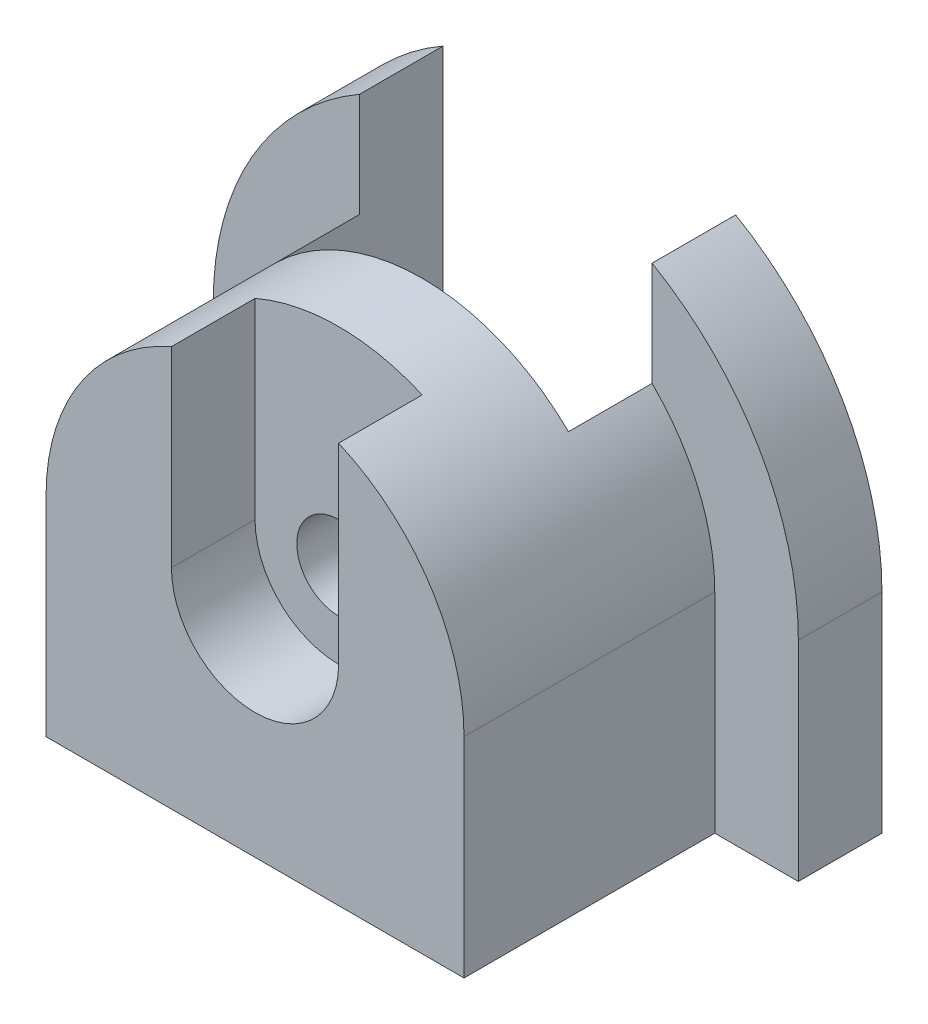
from build123d import *

# Parameters (mm, degrees)
BOSS_EXTRUDE1_DEPTH = 60
SKETCH2_R           = 10
CUT_EXTRUDE1_DEPTH  = 60
CUT_EXTRUDE2_DEPTH  = 20
SKETCH6_R           = 10
CUT_EXTRUDE6_DEPTH  = 20
BOSS_EXTRUDE2_DEPTH = 20
BOSS_EXTRUDE3_DEPTH = 20
SKETCH9_W           = 40
SKETCH9_H           = 10
CUT_EXTRUDE7_DEPTH  = 95


with BuildPart() as part:
    # Sketch1 → Boss-Extrude1 (new body)
    with BuildSketch(Plane.XY):
        with BuildLine():
            ThreePointArc((-50, 0), (0, 50), (50, 0))
            Line((50, 0), (50, -50))
            Line((50, -50), (-50, -50))
            Line((-50, -50), (-50, 0))
        make_face()
    extrude(amount=BOSS_EXTRUDE1_DEPTH)

    # Sketch2 → Cut-Extrude1 (cut)
    with BuildSketch(Plane.XY.offset(60)):
        Circle(SKETCH2_R)
    extrude(amount=-CUT_EXTRUDE1_DEPTH, mode=Mode.SUBTRACT)

    # Sketch3 → Cut-Extrude2 (cut)
    with BuildSketch(Plane.XY.offset(60)):
        with BuildLine():
            Line((-20, 0), (-20, 45.82575695))
            ThreePointArc((-20, 45.82575695), (0, 50), (20, 45.82575695))
            Line((20, 45.82575695), (20, 0))
            ThreePointArc((20, 0), (0, -20), (-20, 0))
        make_face()
    extrude(amount=-CUT_EXTRUDE2_DEPTH, mode=Mode.SUBTRACT)

    # Sketch6 → Cut-Extrude6 (cut)
    with BuildSketch(Plane(origin=(0, 0, 0), x_dir=(-1, 0, 0), z_dir=(0, 0, -1))):
        with BuildLine():
            Line((-35, 35.707142143), (-35, 0))
            ThreePointArc((-35, 0), (0, -35), (35, 0))
            Line((35, 0), (35, 35.707142143))
            ThreePointArc((35, 35.707142143), (0, 50), (-35, 35.707142143))
        make_face()
        Circle(SKETCH6_R, mode=Mode.SUBTRACT)
    extrude(amount=-CUT_EXTRUDE6_DEPTH, mode=Mode.SUBTRACT)

    # Sketch7 → Boss-Extrude2 (add)
    with BuildSketch(Plane(origin=(0, 0, 0), x_dir=(-1, 0, 0), z_dir=(0, 0, -1))):
        with BuildLine():
            Line((-70, -50), (-50, -50))
            Line((-50, -50), (-50, 0))
            ThreePointArc((-50, 0), (-46.097722286, 19.364916731), (-35, 35.707142143))
            Line((-35, 35.707142143), (-35, 60.621778265))
            ThreePointArc((-35, 60.621778265), (-60.621778265, 35), (-70, 0))
            Line((-70, 0), (-70, -50))
        make_face()
        with BuildLine():
            Line((-50, -50), (-35, -50))
            Line((-35, -50), (-35, 0))
            Line((-35, 0), (-35, 35.707142143))
            ThreePointArc((-35, 35.707142143), (-46.097722286, 19.364916731), (-50, 0))
            Line((-50, 0), (-50, -50))
        make_face()
        with BuildLine():
            ThreePointArc((50, 0), (46.097722286, 19.364916731), (35, 35.707142143))
            Line((35, 35.707142143), (35, 0))
            Line((35, 0), (35, -50))
            Line((35, -50), (50, -50))
            Line((50, -50), (50, 0))
        make_face()
        with BuildLine():
            ThreePointArc((70, 0), (60.621778265, 35), (35, 60.621778265))
            Line((35, 60.621778265), (35, 35.707142143))
            ThreePointArc((35, 35.707142143), (46.097722286, 19.364916731), (50, 0))
            Line((50, 0), (50, -50))
            Line((50, -50), (70, -50))
            Line((70, -50), (70, 0))
        make_face()
    extrude(amount=BOSS_EXTRUDE2_DEPTH)

    # Sketch8 → Boss-Extrude3 (add)
    with BuildSketch(Plane(origin=(0, 0, 0), x_dir=(-1, 0, 0), z_dir=(0, 0, -1))):
        with BuildLine():
            Line((-35, -50), (35, -50))
            Line((35, -50), (35, 0))
            ThreePointArc((35, 0), (0, -35), (-35, 0))
            Line((-35, 0), (-35, -50))
        make_face()
    extrude(amount=BOSS_EXTRUDE3_DEPTH)

    # Sketch9 → Cut-Extrude7 (cut)
    with BuildSketch(Plane.XZ.offset(50)):
        with Locations((0, -15)):
            Rectangle(SKETCH9_W, SKETCH9_H)
    extrude(amount=-CUT_EXTRUDE7_DEPTH, mode=Mode.SUBTRACT)


solid = part.part
